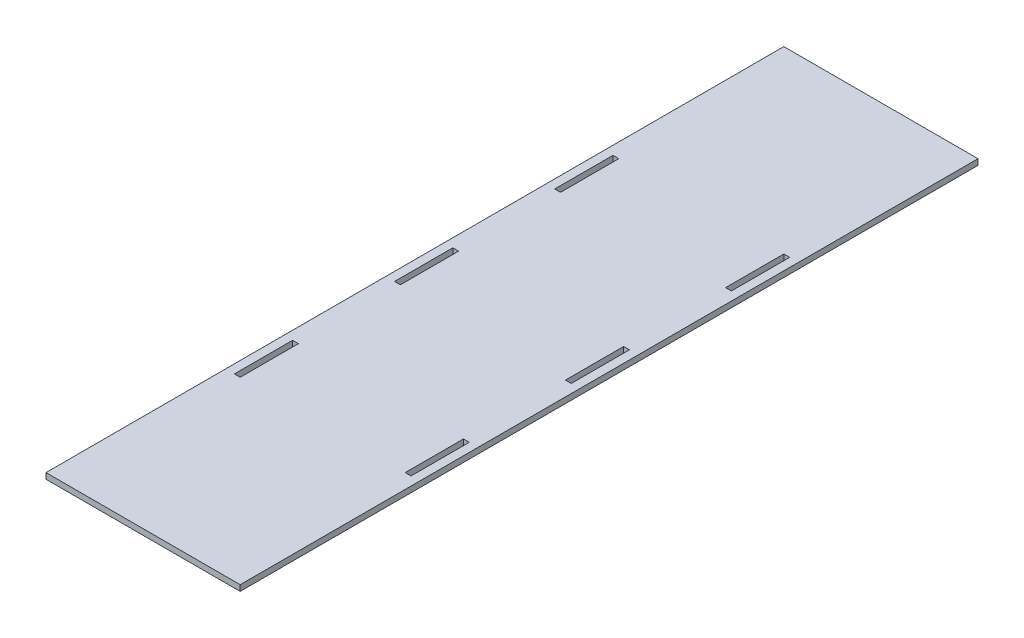
from build123d import *

# Parameters (mm, degrees)
CROQUIS2_W              = 100
CROQUIS2_H              = 380
CROQUIS2_W_2            = 3
CROQUIS2_H_2            = 30
SALIENTE_EXTRUIR1_DEPTH = 3


with BuildPart() as part:
    # Croquis2 → Saliente-Extruir1 (new body)
    with BuildSketch(Plane(origin=(0, 0, 0), x_dir=(1, 0, 0), z_dir=(0, 1, 0))):
        Rectangle(CROQUIS2_W, CROQUIS2_H)
        with Locations((-44, 82.5)):
            Rectangle(CROQUIS2_W_2, CROQUIS2_H_2, mode=Mode.SUBTRACT)
        with Locations((-44, 0)):
            Rectangle(CROQUIS2_W_2, CROQUIS2_H_2, mode=Mode.SUBTRACT)
        with Locations((-44, -82.5)):
            Rectangle(CROQUIS2_W_2, CROQUIS2_H_2, mode=Mode.SUBTRACT)
        with Locations((44, 82.5)):
            Rectangle(CROQUIS2_W_2, CROQUIS2_H_2, mode=Mode.SUBTRACT)
        with Locations((44, 0)):
            Rectangle(CROQUIS2_W_2, CROQUIS2_H_2, mode=Mode.SUBTRACT)
        with Locations((44, -82.5)):
            Rectangle(CROQUIS2_W_2, CROQUIS2_H_2, mode=Mode.SUBTRACT)
    extrude(amount=SALIENTE_EXTRUIR1_DEPTH)


solid = part.part
